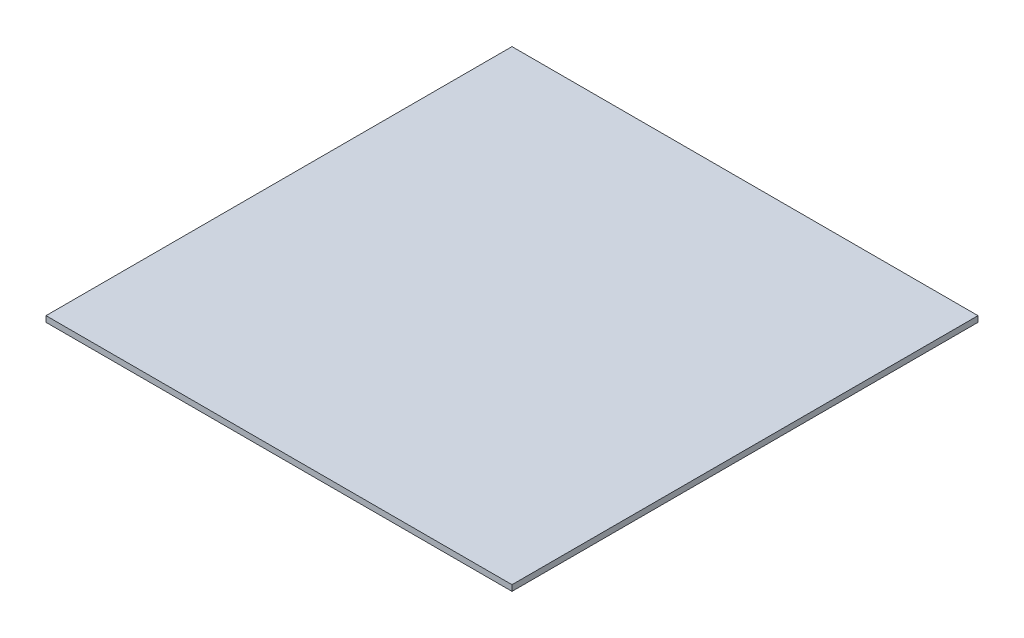
from build123d import *

# Parameters (mm, degrees)
SKETCH1_W           = 4000
SKETCH1_H           = 4000
BOSS_EXTRUDE1_DEPTH = 50


with BuildPart() as part:
    # Sketch1 → Boss-Extrude1 (new body)
    with BuildSketch(Plane(origin=(0, 0, 0), x_dir=(1, 0, 0), z_dir=(0, 1, 0))):
        with Locations((2000, 2000)):
            Rectangle(SKETCH1_W, SKETCH1_H)
    extrude(amount=BOSS_EXTRUDE1_DEPTH)


solid = part.part
